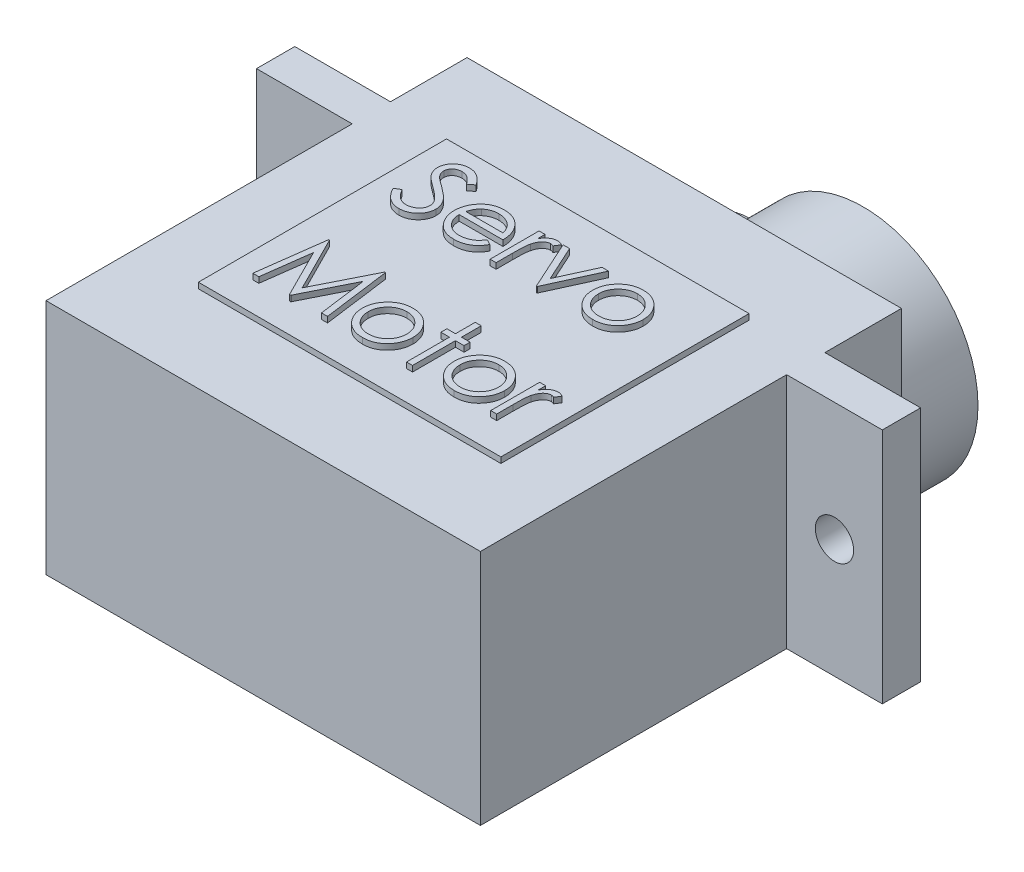
from build123d import *

# Parameters (mm, degrees)
BOSS_EXTRUDE1_DEPTH = 12.4
BOSS_EXTRUDE2_DEPTH = 4
SKETCH3_W           = 15.808123062
SKETCH3_H           = 12.968405358
BOSS_EXTRUDE3_DEPTH = 0.3
BOSS_EXTRUDE4_DEPTH = 0.3
SKETCH5_R           = 2.5
BOSS_EXTRUDE5_DEPTH = 2
CUT_EXTRUDE2_REACH  = 20
SKETCH8_R           = 1


with BuildPart() as part:
    # Sketch1 → Boss-Extrude1 (new body)
    with BuildSketch(Plane(origin=(0, 0, 0), x_dir=(1, 0, 0), z_dir=(0, 1, 0))):
        Polygon((-11.35, 5), (-11.35, -11), (11.35, -11), (11.35, 5), (16.35, 5), (16.35, 7), (11.35, 7), (11.35, 11), (-11.35, 11), (-11.35, 7), (-16.35, 7), (-16.35, 5), align=None)
    extrude(amount=BOSS_EXTRUDE1_DEPTH)

    # Sketch2 → Boss-Extrude2 (add)
    with BuildSketch(Plane(origin=(0, 0, -11), x_dir=(-1, 0, 0), z_dir=(0, 0, -1))):
        with BuildLine():
            Line((0.65, 8.5), (0.104356057, 8.5))
            ThreePointArc((0.104356057, 8.5), (-11.35, 6), (0.104356057, 3.5))
            Line((0.104356057, 3.5), (0.65, 3.5))
            ThreePointArc((0.65, 3.5), (3.15, 6), (0.65, 8.5))
        make_face()
    extrude(amount=BOSS_EXTRUDE2_DEPTH)

    # Sketch3 → Boss-Extrude3 (add)
    with BuildSketch(Plane(origin=(0, 12.4, 0), x_dir=(1, 0, 0), z_dir=(0, 1, 0))):
        Rectangle(SKETCH3_W, SKETCH3_H)
    extrude(amount=BOSS_EXTRUDE3_DEPTH)

    # Sketch4 → Boss-Extrude4 (add)
    with BuildSketch(Plane(origin=(0, 12.7, 0), x_dir=(1, 0, 0), z_dir=(0, 1, 0))):
        with BuildLine():
            Line((-6.767422374, 2.553042472), (-6.471548977, 2.730426286))
            add(Edge.make_bspline(
                [(-6.471548977, 2.730426286), (-6.444030739, 2.684361901), (-6.391306859, 2.596104318), (-6.3033555, 2.476846277), (-6.212222589, 2.37548412), (-6.117233255, 2.292607513), (-6.018967307, 2.227358626), (-5.916783253, 2.181156394), (-5.811025442, 2.152340419), (-5.739051621, 2.148840332), (-5.70311949, 2.147092953)],
                knots=[0, 0, 0, 0, 0.000160901, 0.00030828, 0.000443778, 0.00056903, 0.000685513, 0.000796284, 0.00090427, 0.001011928, 0.001011928, 0.001011928, 0.001011928], degree=3))
            add(Edge.make_bspline(
                [(-5.70311949, 2.147092953), (-5.672432629, 2.147947626), (-5.611595856, 2.149642016), (-5.522033613, 2.165922818), (-5.435051811, 2.190934947), (-5.352443173, 2.226755878), (-5.275347558, 2.270094364), (-5.207740863, 2.322440542), (-5.14929475, 2.381046747), (-5.101485635, 2.446429402), (-5.0648056, 2.516746551), (-5.036613532, 2.588922502), (-5.020968458, 2.66409107), (-5.018611705, 2.714701533), (-5.017422374, 2.740241992)],
                knots=[0, 0, 0, 0, 9.1978e-05, 0.000182347, 0.000272202, 0.000362975, 0.000451852, 0.000536835, 0.000618639, 0.000699414, 0.000778765, 0.000855983, 0.0009312, 0.001007828, 0.001007828, 0.001007828, 0.001007828], degree=3))
            add(Edge.make_bspline(
                [(-5.017422374, 2.740241992), (-5.018896685, 2.769382841), (-5.021893743, 2.82862193), (-5.047225223, 2.916021583), (-5.08707447, 3.002514153), (-5.123837114, 3.056015419), (-5.142923175, 3.083791671)],
                knots=[0, 0, 0, 0, 8.7281e-05, 0.000177429, 0.000270909, 0.000371844, 0.000371844, 0.000371844, 0.000371844], degree=3))
            add(Edge.make_bspline(
                [(-5.142923175, 3.083791671), (-5.15859379, 3.103838495), (-5.191492284, 3.145924293), (-5.248049797, 3.208569529), (-5.314415911, 3.273187948), (-5.388319466, 3.342247005), (-5.472452555, 3.412534801), (-5.564180069, 3.487403079), (-5.665843928, 3.564004656), (-5.737143425, 3.615377222), (-5.773932791, 3.64188462)],
                knots=[0, 0, 0, 0, 7.6319e-05, 0.000160223, 0.000252933, 0.000354147, 0.000463581, 0.000581729, 0.000709336, 0.000845369, 0.000845369, 0.000845369, 0.000845369], degree=3))
            add(Edge.make_bspline(
                [(-5.773932791, 3.64188462), (-5.810756787, 3.668113207), (-5.881161464, 3.71826027), (-5.979620046, 3.792684554), (-6.067664509, 3.860728423), (-6.144903525, 3.923032435), (-6.211303122, 3.97960504), (-6.267386533, 4.029902979), (-6.31172509, 4.07528654), (-6.336380671, 4.104727882), (-6.347450419, 4.117946318)],
                knots=[0, 0, 0, 0, 0.000135623, 0.000259301, 0.000370234, 0.000469439, 0.00055697, 0.000631911, 0.000695377, 0.00074709, 0.00074709, 0.00074709, 0.00074709], degree=3))
            add(Edge.make_bspline(
                [(-6.347450419, 4.117946318), (-6.362922964, 4.138547355), (-6.393351801, 4.179062059), (-6.433517806, 4.242386917), (-6.467656969, 4.307210182), (-6.494419301, 4.373706047), (-6.51695552, 4.440940976), (-6.532113451, 4.509792221), (-6.541604848, 4.57995084), (-6.542576834, 4.62716434), (-6.5430634, 4.650798883)],
                knots=[0, 0, 0, 0, 7.727e-05, 0.000151962, 0.000224716, 0.000296717, 0.00036678, 0.0004372, 0.000507902, 0.000578771, 0.000578771, 0.000578771, 0.000578771], degree=3))
            add(Edge.make_bspline(
                [(-6.5430634, 4.650798883), (-6.541758191, 4.687828657), (-6.539175671, 4.761096721), (-6.517335153, 4.868127551), (-6.48286226, 4.970313969), (-6.434567372, 5.066644302), (-6.372310019, 5.154610283), (-6.300264045, 5.23522377), (-6.214452558, 5.302992352), (-6.120299935, 5.362204411), (-6.017243563, 5.408550336), (-5.90925266, 5.443511316), (-5.796155588, 5.463320574), (-5.719552453, 5.466163339), (-5.680683592, 5.467605774)],
                knots=[0, 0, 0, 0, 0.000110999, 0.000219625, 0.000326272, 0.00043382, 0.000541574, 0.000648775, 0.000756959, 0.000868438, 0.000981703, 0.00109501, 0.001208203, 0.0013248, 0.0013248, 0.0013248, 0.0013248], degree=3))
            add(Edge.make_bspline(
                [(-5.680683592, 5.467605774), (-5.639439492, 5.466183222), (-5.55741814, 5.463354221), (-5.436768924, 5.43875669), (-5.320608208, 5.398056018), (-5.227164943, 5.35186736), (-5.154032182, 5.305735944), (-5.098259449, 5.26371612), (-5.041741998, 5.215341011), (-4.984023944, 5.160481765), (-4.926083284, 5.098635014), (-4.867059832, 5.030224325), (-4.806815563, 4.955667769), (-4.768059703, 4.902443269), (-4.748191605, 4.875157857)],
                knots=[0, 0, 0, 0, 0.000123638, 0.000245877, 0.000367608, 0.000492088, 0.000557638, 0.000626769, 0.000701372, 0.00078072, 0.000865532, 0.000955497, 0.001051745, 0.001152989, 0.001152989, 0.001152989, 0.001152989], degree=3))
            Line((-4.748191605, 4.875157857), (-5.032145932, 4.659913466))
            add(Edge.make_bspline(
                [(-5.032145932, 4.659913466), (-5.049291864, 4.682002156), (-5.082310921, 4.72453981), (-5.132440408, 4.784111125), (-5.179689056, 4.838527605), (-5.226239456, 4.885792733), (-5.269633087, 4.928494866), (-5.31175013, 4.965054623), (-5.351984481, 4.995830218), (-5.402701392, 5.028673778), (-5.46641911, 5.061230282), (-5.546403646, 5.08877936), (-5.629989921, 5.105334422), (-5.686919553, 5.107523309), (-5.715739682, 5.108631415)],
                knots=[0, 0, 0, 0, 8.3877e-05, 0.000161528, 0.000233552, 0.000299993, 0.000360485, 0.000416152, 0.000467195, 0.000512312, 0.000597287, 0.000681099, 0.000765389, 0.000851809, 0.000851809, 0.000851809, 0.000851809], degree=3))
            add(Edge.make_bspline(
                [(-5.715739682, 5.108631415), (-5.751896204, 5.107419715), (-5.821620652, 5.105083065), (-5.920610888, 5.07956308), (-6.009704813, 5.03938122), (-6.086257378, 4.983066242), (-6.149994355, 4.916345249), (-6.196099814, 4.839566394), (-6.223849978, 4.754783991), (-6.227236258, 4.695642335), (-6.228960836, 4.66552244)],
                knots=[0, 0, 0, 0, 0.000108248, 0.000208746, 0.00030443, 0.000399793, 0.000492054, 0.00057947, 0.000666386, 0.000756591, 0.000756591, 0.000756591, 0.000756591], degree=3))
            add(Edge.make_bspline(
                [(-6.228960836, 4.66552244), (-6.228567709, 4.646770962), (-6.227780813, 4.609237342), (-6.216806015, 4.55378592), (-6.202706686, 4.498474581), (-6.180364055, 4.443551998), (-6.149518751, 4.388057639), (-6.109013575, 4.331035901), (-6.058000263, 4.271984193), (-6.018923251, 4.233576819), (-5.998291765, 4.213298883)],
                knots=[0, 0, 0, 0, 5.616e-05, 0.000112411, 0.000169046, 0.000227244, 0.000289691, 0.000359134, 0.000436702, 0.000523463, 0.000523463, 0.000523463, 0.000523463], degree=3))
            add(Edge.make_bspline(
                [(-5.998291765, 4.213298883), (-5.990630393, 4.206461857), (-5.972428726, 4.190218648), (-5.9391528, 4.163626368), (-5.895210002, 4.130823595), (-5.8417478, 4.090236279), (-5.777780439, 4.043154817), (-5.703300883, 3.990181205), (-5.61913935, 3.929595746), (-5.559417434, 3.887238205), (-5.527839041, 3.864841351)],
                knots=[0, 0, 0, 0, 3.0802e-05, 7.3177e-05, 0.000127725, 0.000195314, 0.000274544, 0.000365991, 0.000469501, 0.000585644, 0.000585644, 0.000585644, 0.000585644], degree=3))
            add(Edge.make_bspline(
                [(-5.527839041, 3.864841351), (-5.489853128, 3.837199991), (-5.416298671, 3.783676329), (-5.311641091, 3.703260649), (-5.216747283, 3.624612881), (-5.13128408, 3.548235274), (-5.054407171, 3.474707181), (-4.98696945, 3.403144), (-4.92828377, 3.334058427), (-4.865104552, 3.245485852), (-4.800546732, 3.136704768), (-4.745105225, 3.003426529), (-4.710146877, 2.869630208), (-4.705575362, 2.779703372), (-4.70331981, 2.735334139)],
                knots=[0, 0, 0, 0, 0.000140932, 0.000272896, 0.000395881, 0.000510584, 0.000616697, 0.000714904, 0.000805482, 0.000888372, 0.001041088, 0.001183793, 0.001320341, 0.001453327, 0.001453327, 0.001453327, 0.001453327], degree=3))
            add(Edge.make_bspline(
                [(-4.70331981, 2.735334139), (-4.703976948, 2.703955774), (-4.705278463, 2.64180839), (-4.720239377, 2.550553313), (-4.742159042, 2.461922444), (-4.775196276, 2.377011331), (-4.815519434, 2.294266569), (-4.866685682, 2.215858668), (-4.925993367, 2.14005227), (-4.994027132, 2.068868778), (-5.068473034, 2.003522582), (-5.147156729, 1.945393521), (-5.230207002, 1.896925197), (-5.317173319, 1.857374355), (-5.408075655, 1.826440838), (-5.502883439, 1.804027969), (-5.60175295, 1.790272258), (-5.668953432, 1.788844496), (-5.70311949, 1.788118594)],
                knots=[0, 0, 0, 0, 9.4044e-05, 0.000186263, 0.000276729, 0.000367488, 0.000459046, 0.000552398, 0.000647774, 0.000747454, 0.000847311, 0.000944634, 0.001040472, 0.001135227, 0.001230788, 0.001328063, 0.00142712, 0.00152957, 0.00152957, 0.00152957, 0.00152957], degree=3))
            add(Edge.make_bspline(
                [(-5.70311949, 1.788118594), (-5.729554833, 1.788629776), (-5.782092593, 1.789645701), (-5.859802074, 1.798626982), (-5.935941664, 1.811334085), (-6.009555946, 1.831508155), (-6.081593357, 1.855985132), (-6.151740592, 1.886123465), (-6.220031646, 1.922240666), (-6.286849229, 1.963535691), (-6.352023403, 2.011593435), (-6.414942871, 2.067566932), (-6.477672057, 2.129912437), (-6.538359453, 2.200323), (-6.598232597, 2.277661083), (-6.656111007, 2.362650266), (-6.713192724, 2.45482762), (-6.749008192, 2.519692706), (-6.767422374, 2.553042472)],
                knots=[0, 0, 0, 0, 7.9276e-05, 0.000157554, 0.000234438, 0.000310629, 0.000386236, 0.000462555, 0.000539392, 0.000617798, 0.000698008, 0.000781971, 0.000870217, 0.00096315, 0.001060616, 0.001163492, 0.001271478, 0.00138575, 0.00138575, 0.00138575, 0.00138575], degree=3))
        make_face()
        with BuildLine():
            Line((-1.975956028, 2.685554492), (-1.696909554, 2.539020036))
            add(Edge.make_bspline(
                [(-1.696909554, 2.539020036), (-1.719146149, 2.499576705), (-1.762409757, 2.422835602), (-1.836810505, 2.317403742), (-1.914802578, 2.222556026), (-1.999906546, 2.140826372), (-2.089576225, 2.069574987), (-2.18430888, 2.007237162), (-2.284597697, 1.954118642), (-2.390447422, 1.909366114), (-2.502746973, 1.87495662), (-2.62176849, 1.850652399), (-2.747739985, 1.83562913), (-2.834086165, 1.833883989), (-2.878299778, 1.832990389)],
                knots=[0, 0, 0, 0, 0.000135759, 0.000264133, 0.000386579, 0.000503597, 0.000617365, 0.000729763, 0.000843304, 0.000957371, 0.001074023, 0.001195027, 0.001321389, 0.001453992, 0.001453992, 0.001453992, 0.001453992], degree=3))
            add(Edge.make_bspline(
                [(-2.878299778, 1.832990389), (-2.927441756, 1.834137564), (-3.023303517, 1.836375371), (-3.162843264, 1.855667835), (-3.294222683, 1.887140194), (-3.417434386, 1.931105736), (-3.532176639, 1.98853306), (-3.638677493, 2.058492542), (-3.737497019, 2.140624796), (-3.825521229, 2.23564124), (-3.904765111, 2.337323197), (-3.974690931, 2.443279082), (-4.033148362, 2.553242306), (-4.080700972, 2.66651283), (-4.119105837, 2.782376724), (-4.145872541, 2.901888191), (-4.161302289, 3.024723775), (-4.163666735, 3.107821111), (-4.164858272, 3.14969712)],
                knots=[0, 0, 0, 0, 0.000147371, 0.000287478, 0.000421649, 0.000552053, 0.000679042, 0.000805636, 0.000933558, 0.00106351, 0.001193382, 0.001319977, 0.001443869, 0.001566405, 0.001688128, 0.001809576, 0.001933238, 0.002058864, 0.002058864, 0.002058864, 0.002058864], degree=3))
            add(Edge.make_bspline(
                [(-4.164858272, 3.14969712), (-4.16379913, 3.18899195), (-4.161700052, 3.266869115), (-4.148469265, 3.382134659), (-4.125020972, 3.494163112), (-4.092844648, 3.60304756), (-4.051293401, 3.708605694), (-4.000461182, 3.810901757), (-3.940268804, 3.909826897), (-3.893796131, 3.972230031), (-3.870387118, 4.003663466)],
                knots=[0, 0, 0, 0, 0.000117891, 0.000233644, 0.000347498, 0.000460856, 0.000573868, 0.000687374, 0.000803169, 0.000920699, 0.000920699, 0.000920699, 0.000920699], degree=3))
            add(Edge.make_bspline(
                [(-3.870387118, 4.003663466), (-3.838679435, 4.041532336), (-3.776268488, 4.116070486), (-3.670712133, 4.214008812), (-3.556411937, 4.296052587), (-3.434800311, 4.364059724), (-3.304463837, 4.415733371), (-3.167154545, 4.454240953), (-3.021308959, 4.475818964), (-2.921603738, 4.478866797), (-2.870587438, 4.480426286)],
                knots=[0, 0, 0, 0, 0.000148071, 0.000291452, 0.00043058, 0.000569298, 0.000708346, 0.00085021, 0.000996268, 0.001149307, 0.001149307, 0.001149307, 0.001149307], degree=3))
            add(Edge.make_bspline(
                [(-2.870587438, 4.480426286), (-2.818139833, 4.479072238), (-2.715249587, 4.476415902), (-2.565217466, 4.451789569), (-2.423256749, 4.412737014), (-2.289424245, 4.357583224), (-2.163706384, 4.286423672), (-2.046920335, 4.198281831), (-1.937068822, 4.095863743), (-1.873160243, 4.017100534), (-1.840639522, 3.977020838)],
                knots=[0, 0, 0, 0, 0.000157241, 0.00030847, 0.000454763, 0.000598116, 0.000741606, 0.000886879, 0.001036172, 0.001190853, 0.001190853, 0.001190853, 0.001190853], degree=3))
            add(Edge.make_bspline(
                [(-1.840639522, 3.977020838), (-1.818512583, 3.946817256), (-1.77440599, 3.886611138), (-1.71915889, 3.788439981), (-1.671201495, 3.685729386), (-1.632868534, 3.576819089), (-1.601829033, 3.462999509), (-1.579372214, 3.343456964), (-1.566202596, 3.218227053), (-1.563613898, 3.132900497), (-1.562294169, 3.089400645)],
                knots=[0, 0, 0, 0, 0.000112234, 0.000223721, 0.000337279, 0.000451932, 0.000569628, 0.000690912, 0.000816421, 0.00094695, 0.00094695, 0.00094695, 0.00094695], degree=3))
            Line((-1.562294169, 3.089400645), (-3.850755707, 3.089400645))
            add(Edge.make_bspline(
                [(-3.850755707, 3.089400645), (-3.849216101, 3.055700181), (-3.846188527, 2.989429577), (-3.832073384, 2.892458794), (-3.80982461, 2.800085452), (-3.778555548, 2.71300241), (-3.740688702, 2.630072283), (-3.694302985, 2.551910246), (-3.638963432, 2.478872316), (-3.577237732, 2.410305178), (-3.508530637, 2.349244417), (-3.43624789, 2.294592641), (-3.359354325, 2.248787044), (-3.278456241, 2.211607154), (-3.193684456, 2.182500838), (-3.105012261, 2.162633017), (-3.012614145, 2.149325911), (-2.94962841, 2.147846245), (-2.917562599, 2.147092953)],
                knots=[0, 0, 0, 0, 0.000101159, 0.000198924, 0.000293472, 0.000385722, 0.000476069, 0.000566611, 0.000657757, 0.000750573, 0.000842919, 0.000933083, 0.001022062, 0.001110842, 0.001199752, 0.001290403, 0.001383113, 0.001479259, 0.001479259, 0.001479259, 0.001479259], degree=3))
            add(Edge.make_bspline(
                [(-2.917562599, 2.147092953), (-2.886211451, 2.14770101), (-2.82400476, 2.148907511), (-2.731363903, 2.160639422), (-2.640224375, 2.179609697), (-2.550963392, 2.205499687), (-2.465392546, 2.23707654), (-2.386146996, 2.275179397), (-2.31326678, 2.317329144), (-2.245149814, 2.365538819), (-2.17907882, 2.424547006), (-2.113536334, 2.498182727), (-2.043259681, 2.585270255), (-1.999270088, 2.650815921), (-1.975956028, 2.685554492)],
                knots=[0, 0, 0, 0, 9.4016e-05, 0.000186545, 0.000279636, 0.000373054, 0.000465125, 0.000552934, 0.000636508, 0.000717442, 0.000802858, 0.000901616, 0.001012865, 0.001138311, 0.001138311, 0.001138311, 0.001138311], degree=3))
        make_face()
        with BuildLine():
            add(Edge.make_bspline(
                [(-1.876396733, 3.403503209), (-1.887893358, 3.445166083), (-1.910020659, 3.525353704), (-1.956257024, 3.636394594), (-2.008328564, 3.735082495), (-2.069950296, 3.820662128), (-2.139769021, 3.896665641), (-2.220414204, 3.963084226), (-2.310850097, 4.022501678), (-2.410609238, 4.072654177), (-2.516251023, 4.115344036), (-2.626857215, 4.143969151), (-2.739715003, 4.163578694), (-2.816049289, 4.165404802), (-2.854461637, 4.166323722)],
                knots=[0, 0, 0, 0, 0.000129543, 0.000249328, 0.000360065, 0.000463575, 0.000564789, 0.000668832, 0.000776175, 0.000888744, 0.001003316, 0.001117263, 0.001230914, 0.001346035, 0.001346035, 0.001346035, 0.001346035], degree=3))
            add(Edge.make_bspline(
                [(-2.854461637, 4.166323722), (-2.885811075, 4.165712051), (-2.947782325, 4.164502905), (-3.039083393, 4.153032775), (-3.126763092, 4.134072931), (-3.211468379, 4.108107974), (-3.292089248, 4.073499371), (-3.370284016, 4.032916145), (-3.444064412, 3.983374561), (-3.490205708, 3.945615706), (-3.513516124, 3.926540068)],
                knots=[0, 0, 0, 0, 9.4016e-05, 0.000185849, 0.000275511, 0.000362884, 0.000451173, 0.00053836, 0.000626838, 0.000717174, 0.000717174, 0.000717174, 0.000717174], degree=3))
            add(Edge.make_bspline(
                [(-3.513516124, 3.926540068), (-3.530209406, 3.911445753), (-3.56399254, 3.880898537), (-3.609133062, 3.82826933), (-3.652353535, 3.771517768), (-3.691687187, 3.708472643), (-3.727764774, 3.639851864), (-3.761524751, 3.566234229), (-3.791911163, 3.487061099), (-3.809007273, 3.43188866), (-3.817802983, 3.403503209)],
                knots=[0, 0, 0, 0, 6.7454e-05, 0.00013651, 0.000207604, 0.000281328, 0.000359112, 0.000440057, 0.000524171, 0.000613305, 0.000613305, 0.000613305, 0.000613305], degree=3))
            Line((-3.817802983, 3.403503209), (-1.876396733, 3.403503209))
        make_face(mode=Mode.SUBTRACT)
        with BuildLine():
            Line((-1.023832631, 4.435554492), (-0.709730066, 4.435554492))
            Line((-0.709730066, 4.435554492), (-0.709730066, 4.059052088))
            add(Edge.make_bspline(
                [(-0.709730066, 4.059052088), (-0.686541308, 4.094107916), (-0.642192987, 4.161151915), (-0.568480057, 4.249821216), (-0.492976726, 4.323236263), (-0.415321539, 4.381739782), (-0.334943439, 4.425552901), (-0.253606487, 4.457645936), (-0.170031017, 4.476623251), (-0.113869093, 4.47915691), (-0.085731669, 4.480426286)],
                knots=[0, 0, 0, 0, 0.000126023, 0.000241017, 0.000345147, 0.000441342, 0.00053171, 0.000618946, 0.000702978, 0.000787349, 0.000787349, 0.000787349, 0.000787349], degree=3))
            add(Edge.make_bspline(
                [(-0.085731669, 4.480426286), (-0.063905343, 4.47923576), (-0.018996257, 4.476786174), (0.048986332, 4.459575349), (0.119029784, 4.432097327), (0.164172172, 4.406257104), (0.187705831, 4.392786062)],
                knots=[0, 0, 0, 0, 6.5445e-05, 0.000134658, 0.00020926, 0.000290509, 0.000290509, 0.000290509, 0.000290509], degree=3))
            Line((0.187705831, 4.392786062), (0.015229869, 4.120750806))
            add(Edge.make_bspline(
                [(0.015229869, 4.120750806), (0.000120848, 4.127491072), (-0.028558966, 4.140285387), (-0.070513533, 4.155427397), (-0.109194869, 4.164343313), (-0.133838428, 4.165694031), (-0.145327022, 4.166323722)],
                knots=[0, 0, 0, 0, 4.9621e-05, 9.4191e-05, 0.00013366, 0.000168129, 0.000168129, 0.000168129, 0.000168129], degree=3))
            add(Edge.make_bspline(
                [(-0.145327022, 4.166323722), (-0.170532755, 4.164643685), (-0.221945145, 4.161216896), (-0.297429644, 4.134278088), (-0.37067685, 4.090752848), (-0.428848512, 4.042481736), (-0.473890765, 3.995933939), (-0.506030991, 3.955285536), (-0.535513738, 3.909706904), (-0.563683958, 3.859977221), (-0.589350252, 3.805247375), (-0.613304921, 3.746064161), (-0.634963784, 3.682359032), (-0.647314029, 3.637976512), (-0.653640323, 3.615241992)],
                knots=[0, 0, 0, 0, 7.549e-05, 0.000153978, 0.000237553, 0.000330197, 0.000379784, 0.000431685, 0.000485357, 0.000542493, 0.000603021, 0.000666557, 0.00073396, 0.000804745, 0.000804745, 0.000804745, 0.000804745], degree=3))
            add(Edge.make_bspline(
                [(-0.653640323, 3.615241992), (-0.658372716, 3.594964818), (-0.668854608, 3.550052419), (-0.679046146, 3.474703895), (-0.689115664, 3.385680236), (-0.696212282, 3.282733643), (-0.702790324, 3.166121199), (-0.706500406, 3.035665253), (-0.709603547, 2.891231902), (-0.709686614, 2.790257549), (-0.709730066, 2.737437504)],
                knots=[0, 0, 0, 0, 6.2435e-05, 0.000138289, 0.000227871, 0.000331224, 0.000447781, 0.000578258, 0.000722716, 0.000881171, 0.000881171, 0.000881171, 0.000881171], degree=3))
            Line((-0.709730066, 2.737437504), (-0.709730066, 1.877862184))
            Line((-0.709730066, 1.877862184), (-1.023832631, 1.877862184))
            Line((-1.023832631, 1.877862184), (-1.023832631, 4.435554492))
        make_face()
        Polygon((0.232577626, 4.435554492), (0.572621696, 4.435554492), (1.42168019, 2.573375004), (2.270738684, 4.435554492), (2.610782754, 4.435554492), (1.444116087, 1.877862184), (1.399244293, 1.877862184), align=None)
        with BuildLine():
            add(Edge.make_bspline(
                [(4.384620895, 4.480426286), (4.432612168, 4.479404395), (4.526711325, 4.477400716), (4.664519211, 4.455985751), (4.796064347, 4.423238386), (4.921850539, 4.377966824), (5.040266835, 4.317284874), (5.153038079, 4.244875583), (5.259855088, 4.159092989), (5.323878117, 4.092734921), (5.356375703, 4.059052088)],
                knots=[0, 0, 0, 0, 0.000143868, 0.000282091, 0.000417278, 0.000550139, 0.000682145, 0.000815559, 0.000951665, 0.001091969, 0.001091969, 0.001091969, 0.001091969], degree=3))
            add(Edge.make_bspline(
                [(5.356375703, 4.059052088), (5.384357657, 4.026838102), (5.439780037, 3.96303356), (5.510845756, 3.859577947), (5.572067316, 3.752437846), (5.621130277, 3.640190519), (5.659815301, 3.523815848), (5.687280997, 3.402913837), (5.703617932, 3.27775149), (5.705820899, 3.192747652), (5.7069366, 3.14969712)],
                knots=[0, 0, 0, 0, 0.000127922, 0.000253368, 0.000375813, 0.000497617, 0.000620225, 0.000743195, 0.000869033, 0.000998161, 0.000998161, 0.000998161, 0.000998161], degree=3))
            add(Edge.make_bspline(
                [(5.7069366, 3.14969712), (5.705955263, 3.106397062), (5.704016095, 3.020834129), (5.685672478, 2.894814763), (5.657141392, 2.77261994), (5.616309554, 2.654761247), (5.563951445, 2.540878419), (5.500060757, 2.43146887), (5.42418914, 2.326316737), (5.338185143, 2.226314898), (5.243133267, 2.134148684), (5.140017119, 2.053820414), (5.030863085, 1.98499889), (4.914219732, 1.929562474), (4.791152245, 1.885852774), (4.661395177, 1.855152757), (4.525150107, 1.836591073), (4.432122885, 1.8342075), (4.384620895, 1.832990389)],
                knots=[0, 0, 0, 0, 0.000129829, 0.000256548, 0.000381202, 0.000505812, 0.000630045, 0.000756669, 0.000885282, 0.001018518, 0.001151902, 0.001281775, 0.001409974, 0.001538236, 0.001668405, 0.001801048, 0.001937587, 0.002080055, 0.002080055, 0.002080055, 0.002080055], degree=3))
            add(Edge.make_bspline(
                [(4.384620895, 1.832990389), (4.336886176, 1.834211585), (4.243395316, 1.83660336), (4.106669334, 1.855080642), (3.976679715, 1.885838625), (3.853451116, 1.929706118), (3.73630627, 1.985000661), (3.626519773, 2.053612351), (3.523319857, 2.134172506), (3.428247873, 2.226308443), (3.342249267, 2.3263184), (3.266376259, 2.431468438), (3.202485933, 2.540878532), (3.150127729, 2.654761217), (3.109295916, 2.772619948), (3.080764823, 2.894814761), (3.062421209, 3.020834129), (3.06048204, 3.106397062), (3.059500703, 3.14969712)],
                knots=[0, 0, 0, 0, 0.000143168, 0.000280402, 0.000413045, 0.000543214, 0.000672108, 0.000800903, 0.000930775, 0.00106416, 0.001197395, 0.001326009, 0.001452632, 0.001576866, 0.001701476, 0.00182613, 0.001952849, 0.002082678, 0.002082678, 0.002082678, 0.002082678], degree=3))
            add(Edge.make_bspline(
                [(3.059500703, 3.14969712), (3.060624013, 3.192513666), (3.062847975, 3.277283068), (3.079168484, 3.402210129), (3.10652704, 3.522907518), (3.145258437, 3.638832994), (3.194773627, 3.75058843), (3.255134915, 3.857993261), (3.326925548, 3.960981061), (3.382127499, 4.024703141), (3.4100616, 4.056948722)],
                knots=[0, 0, 0, 0, 0.000128428, 0.000254265, 0.000377235, 0.000499178, 0.000620341, 0.000743397, 0.000868267, 0.000996189, 0.000996189, 0.000996189, 0.000996189], degree=3))
            add(Edge.make_bspline(
                [(3.4100616, 4.056948722), (3.442510191, 4.090923662), (3.506326055, 4.157741358), (3.613674783, 4.243273882), (3.726168604, 4.317189956), (3.84589353, 4.376666171), (3.971576388, 4.423504689), (4.103795631, 4.456070204), (4.242071146, 4.477323559), (4.336630767, 4.479381737), (4.384620895, 4.480426286)],
                knots=[0, 0, 0, 0, 0.000140798, 0.000276904, 0.000410699, 0.000543958, 0.000677061, 0.000812248, 0.000951858, 0.001095726, 0.001095726, 0.001095726, 0.001095726], degree=3))
        make_face()
        with BuildLine():
            add(Edge.make_bspline(
                [(4.383218651, 4.166323722), (4.34928104, 4.165359131), (4.282281911, 4.163454848), (4.183662327, 4.148970943), (4.088722173, 4.126023439), (3.997281329, 4.093419383), (3.909648156, 4.051320484), (3.825738754, 3.999612124), (3.745306314, 3.938979167), (3.669924251, 3.869516496), (3.600741938, 3.793637501), (3.540263962, 3.712789142), (3.488838856, 3.628282796), (3.445998697, 3.540030585), (3.414091508, 3.447138171), (3.390918486, 3.35065754), (3.376448246, 3.250392123), (3.374561867, 3.182231105), (3.373603267, 3.147593754)],
                knots=[0, 0, 0, 0, 0.000101781, 0.000200935, 0.000298373, 0.000394396, 0.000491609, 0.000589491, 0.000689611, 0.000793323, 0.000896562, 0.000997243, 0.001095722, 0.001192936, 0.001290943, 0.001389744, 0.001490285, 0.001594167, 0.001594167, 0.001594167, 0.001594167], degree=3))
            add(Edge.make_bspline(
                [(3.373603267, 3.147593754), (3.375210091, 3.102841727), (3.378399335, 3.014017322), (3.404334571, 2.883206199), (3.447720851, 2.757624347), (3.506308131, 2.638007961), (3.57971435, 2.527335683), (3.666201416, 2.428664198), (3.764841117, 2.343478387), (3.874457617, 2.272797541), (3.992811935, 2.216637786), (4.118068256, 2.17683881), (4.24870895, 2.150967118), (4.337989681, 2.148395643), (4.383218651, 2.147092953)],
                knots=[0, 0, 0, 0, 0.000134178, 0.000266319, 0.000398243, 0.00053182, 0.000664828, 0.000795487, 0.000924236, 0.001054533, 0.001185628, 0.001316003, 0.001448011, 0.001583547, 0.001583547, 0.001583547, 0.001583547], degree=3))
            add(Edge.make_bspline(
                [(4.383218651, 2.147092953), (4.42844502, 2.148403233), (4.517720616, 2.15098969), (4.648179793, 2.17670851), (4.773093765, 2.216812171), (4.891325153, 2.272734381), (5.000891756, 2.343746795), (5.100240877, 2.428183172), (5.185989489, 2.527597024), (5.259323093, 2.638154553), (5.318869836, 2.757438905), (5.362053038, 2.883229377), (5.388050624, 3.014011419), (5.391231453, 3.10283975), (5.392834036, 3.147593754)],
                knots=[0, 0, 0, 0, 0.000135536, 0.000267545, 0.000397252, 0.000528347, 0.000658644, 0.000787925, 0.000918122, 0.00105113, 0.001185017, 0.001316942, 0.001449082, 0.00158326, 0.00158326, 0.00158326, 0.00158326], degree=3))
            add(Edge.make_bspline(
                [(5.392834036, 3.147593754), (5.391875766, 3.182231312), (5.389990037, 3.250392738), (5.375515073, 3.350655191), (5.352359533, 3.447146788), (5.320387916, 3.539998791), (5.277733902, 3.628511296), (5.225317109, 3.712541023), (5.165086083, 3.793917569), (5.095068962, 3.869271209), (5.019765585, 3.939006246), (4.939300546, 3.999635635), (4.855515568, 4.051093231), (4.768136985, 4.093779471), (4.676684417, 4.125726812), (4.581877288, 4.149103443), (4.483678478, 4.16339364), (4.416919435, 4.165340781), (4.383218651, 4.166323722)],
                knots=[0, 0, 0, 0, 0.000103882, 0.000204424, 0.000303225, 0.000401232, 0.000498445, 0.000597291, 0.000697972, 0.000801684, 0.000905395, 0.001005516, 0.001103397, 0.001199979, 0.001296663, 0.00139342, 0.001492573, 0.001593654, 0.001593654, 0.001593654, 0.001593654], degree=3))
        make_face(mode=Mode.SUBTRACT)
        Polygon((-6.587935195, -4.955471149), (-6.125895932, -1.455471149), (-6.081024137, -1.455471149), (-4.636012118, -4.327266021), (-3.194505707, -1.455471149), (-3.148932791, -1.455471149), (-2.684089041, -4.955471149), (-2.999593849, -4.955471149), (-3.334730066, -2.437041662), (-4.598151541, -4.955471149), (-4.668964842, -4.955471149), (-5.937294169, -2.431432688), (-6.271729265, -4.955471149), align=None)
        with BuildLine():
            add(Edge.make_bspline(
                [(-0.82050731, -2.352907047), (-0.772516037, -2.353928938), (-0.67841688, -2.355932617), (-0.540608994, -2.377347582), (-0.409063858, -2.410094947), (-0.283277666, -2.455366509), (-0.16486137, -2.51604846), (-0.052090126, -2.588457751), (0.054726883, -2.674240344), (0.118749912, -2.740598413), (0.151247498, -2.774281246)],
                knots=[0, 0, 0, 0, 0.000143868, 0.000282091, 0.000417278, 0.000550139, 0.000682145, 0.000815559, 0.000951665, 0.001091969, 0.001091969, 0.001091969, 0.001091969], degree=3))
            add(Edge.make_bspline(
                [(0.151247498, -2.774281246), (0.179229452, -2.806495231), (0.234651832, -2.870299774), (0.305717551, -2.973755387), (0.366939111, -3.080895487), (0.416002072, -3.193142814), (0.454687096, -3.309517485), (0.482152792, -3.430419496), (0.498489727, -3.555581843), (0.500692694, -3.640585681), (0.501808395, -3.683636214)],
                knots=[0, 0, 0, 0, 0.000127922, 0.000253368, 0.000375813, 0.000497617, 0.000620225, 0.000743195, 0.000869033, 0.000998161, 0.000998161, 0.000998161, 0.000998161], degree=3))
            add(Edge.make_bspline(
                [(0.501808395, -3.683636214), (0.500827058, -3.726936271), (0.498887889, -3.812499205), (0.480544273, -3.93851857), (0.452013187, -4.060713393), (0.411181349, -4.178572087), (0.35882324, -4.292454914), (0.294932552, -4.401864464), (0.219060935, -4.507016597), (0.133056938, -4.607018435), (0.038005062, -4.69918465), (-0.065111086, -4.779512919), (-0.17426512, -4.848334444), (-0.290908473, -4.903770859), (-0.41397596, -4.94748056), (-0.543733028, -4.978180576), (-0.679978098, -4.99674226), (-0.77300532, -4.999125833), (-0.82050731, -5.000342944)],
                knots=[0, 0, 0, 0, 0.000129829, 0.000256548, 0.000381202, 0.000505812, 0.000630045, 0.000756669, 0.000885282, 0.001018518, 0.001151902, 0.001281775, 0.001409974, 0.001538236, 0.001668405, 0.001801048, 0.001937587, 0.002080055, 0.002080055, 0.002080055, 0.002080055], degree=3))
            add(Edge.make_bspline(
                [(-0.82050731, -5.000342944), (-0.86824203, -4.999121748), (-0.961732889, -4.996729974), (-1.098458871, -4.978252691), (-1.22844849, -4.947494708), (-1.351677089, -4.903627216), (-1.468821936, -4.848332672), (-1.578608433, -4.779720982), (-1.681808348, -4.699160827), (-1.776880333, -4.60702489), (-1.862878938, -4.507014934), (-1.938751946, -4.401864895), (-2.002642272, -4.292454802), (-2.055000476, -4.178572117), (-2.095832289, -4.060713385), (-2.124363382, -3.938518573), (-2.142706996, -3.812499204), (-2.144646165, -3.726936271), (-2.145627502, -3.683636214)],
                knots=[0, 0, 0, 0, 0.000143168, 0.000280402, 0.000413045, 0.000543214, 0.000672108, 0.000800903, 0.000930775, 0.00106416, 0.001197395, 0.001326009, 0.001452632, 0.001576866, 0.001701476, 0.00182613, 0.001952849, 0.002082678, 0.002082678, 0.002082678, 0.002082678], degree=3))
            add(Edge.make_bspline(
                [(-2.145627502, -3.683636214), (-2.144504192, -3.640819668), (-2.142280231, -3.556050265), (-2.125959721, -3.431123205), (-2.098601165, -3.310425816), (-2.059869769, -3.19450034), (-2.010354578, -3.082744904), (-1.94999329, -2.975340073), (-1.878202657, -2.872352272), (-1.823000706, -2.808630192), (-1.795066605, -2.776384611)],
                knots=[0, 0, 0, 0, 0.000128428, 0.000254265, 0.000377235, 0.000499178, 0.000620341, 0.000743397, 0.000868267, 0.000996189, 0.000996189, 0.000996189, 0.000996189], degree=3))
            add(Edge.make_bspline(
                [(-1.795066605, -2.776384611), (-1.762618014, -2.742409672), (-1.69880215, -2.675591976), (-1.591453422, -2.590059451), (-1.478959601, -2.516143378), (-1.359234675, -2.456667162), (-1.233551817, -2.409828644), (-1.101332575, -2.377263129), (-0.963057059, -2.356009774), (-0.868497438, -2.353951597), (-0.82050731, -2.352907047)],
                knots=[0, 0, 0, 0, 0.000140798, 0.000276904, 0.000410699, 0.000543958, 0.000677061, 0.000812248, 0.000951858, 0.001095726, 0.001095726, 0.001095726, 0.001095726], degree=3))
        make_face()
        with BuildLine():
            add(Edge.make_bspline(
                [(-0.821909554, -2.667009611), (-0.855847165, -2.667974203), (-0.922846294, -2.669878485), (-1.021465878, -2.68436239), (-1.116406032, -2.707309894), (-1.207846876, -2.73991395), (-1.295480049, -2.782012849), (-1.379389451, -2.833721209), (-1.459821891, -2.894354166), (-1.535203954, -2.963816838), (-1.604386267, -3.039695832), (-1.664864243, -3.120544191), (-1.71628935, -3.205050537), (-1.759129509, -3.293302748), (-1.791036697, -3.386195162), (-1.814209719, -3.482675793), (-1.82867996, -3.58294121), (-1.830566338, -3.651102228), (-1.831524938, -3.685739579)],
                knots=[0, 0, 0, 0, 0.000101781, 0.000200935, 0.000298373, 0.000394396, 0.000491609, 0.000589491, 0.000689611, 0.000793323, 0.000896562, 0.000997243, 0.001095722, 0.001192936, 0.001290943, 0.001389744, 0.001490285, 0.001594167, 0.001594167, 0.001594167, 0.001594167], degree=3))
            add(Edge.make_bspline(
                [(-1.831524938, -3.685739579), (-1.829918115, -3.730491606), (-1.82672887, -3.819316012), (-1.800793634, -3.950127134), (-1.757407354, -4.075708986), (-1.698820074, -4.195325372), (-1.625413855, -4.30599765), (-1.538926789, -4.404669135), (-1.440287088, -4.489854946), (-1.330670588, -4.560535792), (-1.21231627, -4.616695548), (-1.087059949, -4.656494523), (-0.956419255, -4.682366216), (-0.867138524, -4.68493769), (-0.821909554, -4.68624038)],
                knots=[0, 0, 0, 0, 0.000134178, 0.000266319, 0.000398243, 0.00053182, 0.000664828, 0.000795487, 0.000924236, 0.001054533, 0.001185628, 0.001316003, 0.001448011, 0.001583547, 0.001583547, 0.001583547, 0.001583547], degree=3))
            add(Edge.make_bspline(
                [(-0.821909554, -4.68624038), (-0.776683185, -4.6849301), (-0.687407589, -4.682343643), (-0.556948412, -4.656624823), (-0.43203444, -4.616521163), (-0.313803053, -4.560598953), (-0.204236449, -4.489586538), (-0.104887328, -4.405150161), (-0.019138717, -4.30573631), (0.054194888, -4.195178781), (0.113741631, -4.075894429), (0.156924833, -3.950103956), (0.182922419, -3.819321914), (0.186103247, -3.730493584), (0.187705831, -3.685739579)],
                knots=[0, 0, 0, 0, 0.000135536, 0.000267545, 0.000397252, 0.000528347, 0.000658644, 0.000787925, 0.000918122, 0.00105113, 0.001185017, 0.001316942, 0.001449082, 0.00158326, 0.00158326, 0.00158326, 0.00158326], degree=3))
            add(Edge.make_bspline(
                [(0.187705831, -3.685739579), (0.186747561, -3.651102021), (0.184861832, -3.582940596), (0.170386867, -3.482678142), (0.147231328, -3.386186545), (0.115259711, -3.293334542), (0.072605697, -3.204822038), (0.020188904, -3.120792311), (-0.040042122, -3.039415765), (-0.110059243, -2.964062124), (-0.185362621, -2.894327087), (-0.265827659, -2.833697698), (-0.349612637, -2.782240102), (-0.43699122, -2.739553862), (-0.528443788, -2.707606522), (-0.623250917, -2.68422989), (-0.721449727, -2.669939693), (-0.78820877, -2.667992552), (-0.821909554, -2.667009611)],
                knots=[0, 0, 0, 0, 0.000103882, 0.000204424, 0.000303225, 0.000401232, 0.000498445, 0.000597291, 0.000697972, 0.000801684, 0.000905395, 0.001005516, 0.001103397, 0.001199979, 0.001296663, 0.00139342, 0.001492573, 0.001593654, 0.001593654, 0.001593654, 0.001593654], degree=3))
        make_face(mode=Mode.SUBTRACT)
        Polygon((1.444116087, -1.36572756), (1.758218651, -1.36572756), (1.758218651, -2.397778842), (2.2069366, -2.397778842), (2.2069366, -2.711881406), (1.758218651, -2.711881406), (1.758218651, -4.955471149), (1.444116087, -4.955471149), (1.444116087, -2.711881406), (0.995398139, -2.711881406), (0.995398139, -2.397778842), (1.444116087, -2.397778842), align=None)
        with BuildLine():
            add(Edge.make_bspline(
                [(3.980774741, -2.352907047), (4.028766014, -2.353928938), (4.122865172, -2.355932617), (4.260673058, -2.377347582), (4.392218193, -2.410094947), (4.518004386, -2.455366509), (4.636420681, -2.51604846), (4.749191925, -2.588457751), (4.856008934, -2.674240344), (4.920031963, -2.740598413), (4.952529549, -2.774281246)],
                knots=[0, 0, 0, 0, 0.000143868, 0.000282091, 0.000417278, 0.000550139, 0.000682145, 0.000815559, 0.000951665, 0.001091969, 0.001091969, 0.001091969, 0.001091969], degree=3))
            add(Edge.make_bspline(
                [(4.952529549, -2.774281246), (4.980511503, -2.806495231), (5.035933883, -2.870299774), (5.106999602, -2.973755387), (5.168221162, -3.080895487), (5.217284123, -3.193142814), (5.255969147, -3.309517485), (5.283434843, -3.430419496), (5.299771778, -3.555581843), (5.301974745, -3.640585681), (5.303090446, -3.683636214)],
                knots=[0, 0, 0, 0, 0.000127922, 0.000253368, 0.000375813, 0.000497617, 0.000620225, 0.000743195, 0.000869033, 0.000998161, 0.000998161, 0.000998161, 0.000998161], degree=3))
            add(Edge.make_bspline(
                [(5.303090446, -3.683636214), (5.302109109, -3.726936271), (5.300169941, -3.812499205), (5.281826324, -3.93851857), (5.253295238, -4.060713393), (5.2124634, -4.178572087), (5.160105291, -4.292454914), (5.096214603, -4.401864464), (5.020342986, -4.507016597), (4.93433899, -4.607018435), (4.839287113, -4.69918465), (4.736170965, -4.779512919), (4.627016931, -4.848334444), (4.510373578, -4.903770859), (4.387306091, -4.94748056), (4.257549023, -4.978180576), (4.121303953, -4.99674226), (4.028276731, -4.999125833), (3.980774741, -5.000342944)],
                knots=[0, 0, 0, 0, 0.000129829, 0.000256548, 0.000381202, 0.000505812, 0.000630045, 0.000756669, 0.000885282, 0.001018518, 0.001151902, 0.001281775, 0.001409974, 0.001538236, 0.001668405, 0.001801048, 0.001937587, 0.002080055, 0.002080055, 0.002080055, 0.002080055], degree=3))
            add(Edge.make_bspline(
                [(3.980774741, -5.000342944), (3.933040022, -4.999121748), (3.839549162, -4.996729974), (3.70282318, -4.978252691), (3.572833561, -4.947494708), (3.449604963, -4.903627216), (3.332460116, -4.848332672), (3.222673619, -4.779720982), (3.119473703, -4.699160827), (3.024401719, -4.60702489), (2.938403113, -4.507014934), (2.862530105, -4.401864895), (2.798639779, -4.292454802), (2.746281575, -4.178572117), (2.705449762, -4.060713385), (2.676918669, -3.938518573), (2.658575055, -3.812499204), (2.656635886, -3.726936271), (2.655654549, -3.683636214)],
                knots=[0, 0, 0, 0, 0.000143168, 0.000280402, 0.000413045, 0.000543214, 0.000672108, 0.000800903, 0.000930775, 0.00106416, 0.001197395, 0.001326009, 0.001452632, 0.001576866, 0.001701476, 0.00182613, 0.001952849, 0.002082678, 0.002082678, 0.002082678, 0.002082678], degree=3))
            add(Edge.make_bspline(
                [(2.655654549, -3.683636214), (2.656777859, -3.640819668), (2.659001821, -3.556050265), (2.67532233, -3.431123205), (2.702680886, -3.310425816), (2.741412283, -3.19450034), (2.790927474, -3.082744904), (2.851288762, -2.975340073), (2.923079394, -2.872352272), (2.978281346, -2.808630192), (3.006215446, -2.776384611)],
                knots=[0, 0, 0, 0, 0.000128428, 0.000254265, 0.000377235, 0.000499178, 0.000620341, 0.000743397, 0.000868267, 0.000996189, 0.000996189, 0.000996189, 0.000996189], degree=3))
            add(Edge.make_bspline(
                [(3.006215446, -2.776384611), (3.038664037, -2.742409672), (3.102479901, -2.675591976), (3.209828629, -2.590059451), (3.32232245, -2.516143378), (3.442047376, -2.456667162), (3.567730234, -2.409828644), (3.699949477, -2.377263129), (3.838224992, -2.356009774), (3.932784613, -2.353951597), (3.980774741, -2.352907047)],
                knots=[0, 0, 0, 0, 0.000140798, 0.000276904, 0.000410699, 0.000543958, 0.000677061, 0.000812248, 0.000951858, 0.001095726, 0.001095726, 0.001095726, 0.001095726], degree=3))
        make_face()
        with BuildLine():
            add(Edge.make_bspline(
                [(3.979372498, -2.667009611), (3.945434886, -2.667974203), (3.878435758, -2.669878485), (3.779816173, -2.68436239), (3.684876019, -2.707309894), (3.593435175, -2.73991395), (3.505802002, -2.782012849), (3.4218926, -2.833721209), (3.34146016, -2.894354166), (3.266078097, -2.963816838), (3.196895785, -3.039695832), (3.136417808, -3.120544191), (3.084992702, -3.205050537), (3.042152543, -3.293302748), (3.010245355, -3.386195162), (2.987072332, -3.482675793), (2.972602092, -3.58294121), (2.970715713, -3.651102228), (2.969757113, -3.685739579)],
                knots=[0, 0, 0, 0, 0.000101781, 0.000200935, 0.000298373, 0.000394396, 0.000491609, 0.000589491, 0.000689611, 0.000793323, 0.000896562, 0.000997243, 0.001095722, 0.001192936, 0.001290943, 0.001389744, 0.001490285, 0.001594167, 0.001594167, 0.001594167, 0.001594167], degree=3))
            add(Edge.make_bspline(
                [(2.969757113, -3.685739579), (2.971363937, -3.730491606), (2.974553181, -3.819316012), (3.000488418, -3.950127134), (3.043874697, -4.075708986), (3.102461977, -4.195325372), (3.175868196, -4.30599765), (3.262355262, -4.404669135), (3.360994963, -4.489854946), (3.470611463, -4.560535792), (3.588965781, -4.616695548), (3.714222102, -4.656494523), (3.844862796, -4.682366216), (3.934143527, -4.68493769), (3.979372498, -4.68624038)],
                knots=[0, 0, 0, 0, 0.000134178, 0.000266319, 0.000398243, 0.00053182, 0.000664828, 0.000795487, 0.000924236, 0.001054533, 0.001185628, 0.001316003, 0.001448011, 0.001583547, 0.001583547, 0.001583547, 0.001583547], degree=3))
            add(Edge.make_bspline(
                [(3.979372498, -4.68624038), (4.024598867, -4.6849301), (4.113874463, -4.682343643), (4.244333639, -4.656624823), (4.369247611, -4.616521163), (4.487478999, -4.560598953), (4.597045602, -4.489586538), (4.696394724, -4.405150161), (4.782143335, -4.30573631), (4.85547694, -4.195178781), (4.915023682, -4.075894429), (4.958206884, -3.950103956), (4.98420447, -3.819321914), (4.987385299, -3.730493584), (4.988987882, -3.685739579)],
                knots=[0, 0, 0, 0, 0.000135536, 0.000267545, 0.000397252, 0.000528347, 0.000658644, 0.000787925, 0.000918122, 0.00105113, 0.001185017, 0.001316942, 0.001449082, 0.00158326, 0.00158326, 0.00158326, 0.00158326], degree=3))
            add(Edge.make_bspline(
                [(4.988987882, -3.685739579), (4.988029612, -3.651102021), (4.986143883, -3.582940596), (4.971668919, -3.482678142), (4.948513379, -3.386186545), (4.916541762, -3.293334542), (4.873887748, -3.204822038), (4.821470955, -3.120792311), (4.761239929, -3.039415765), (4.691222809, -2.964062124), (4.615919431, -2.894327087), (4.535454393, -2.833697698), (4.451669414, -2.782240102), (4.364290831, -2.739553862), (4.272838264, -2.707606522), (4.178031134, -2.68422989), (4.079832325, -2.669939693), (4.013073281, -2.667992552), (3.979372498, -2.667009611)],
                knots=[0, 0, 0, 0, 0.000103882, 0.000204424, 0.000303225, 0.000401232, 0.000498445, 0.000597291, 0.000697972, 0.000801684, 0.000905395, 0.001005516, 0.001103397, 0.001199979, 0.001296663, 0.00139342, 0.001492573, 0.001593654, 0.001593654, 0.001593654, 0.001593654], degree=3))
        make_face(mode=Mode.SUBTRACT)
        with BuildLine():
            Line((5.841551985, -2.397778842), (6.155654549, -2.397778842))
            Line((6.155654549, -2.397778842), (6.155654549, -2.774281246))
            add(Edge.make_bspline(
                [(6.155654549, -2.774281246), (6.178843308, -2.739225417), (6.223191629, -2.672181418), (6.296904558, -2.583512117), (6.372407889, -2.51009707), (6.450063077, -2.451593552), (6.530441176, -2.407780433), (6.611778128, -2.375687398), (6.695353598, -2.356710083), (6.751515522, -2.354176424), (6.779652946, -2.352907047)],
                knots=[0, 0, 0, 0, 0.000126023, 0.000241017, 0.000345147, 0.000441342, 0.00053171, 0.000618946, 0.000702978, 0.000787349, 0.000787349, 0.000787349, 0.000787349], degree=3))
            add(Edge.make_bspline(
                [(6.779652946, -2.352907047), (6.801479273, -2.354097574), (6.846388358, -2.356547159), (6.914370948, -2.373757984), (6.9844144, -2.401236007), (7.029556787, -2.427076229), (7.053090446, -2.440547271)],
                knots=[0, 0, 0, 0, 6.5445e-05, 0.000134658, 0.00020926, 0.000290509, 0.000290509, 0.000290509, 0.000290509], degree=3))
            Line((7.053090446, -2.440547271), (6.880614485, -2.712582528))
            add(Edge.make_bspline(
                [(6.880614485, -2.712582528), (6.865505464, -2.705842262), (6.836825649, -2.693047946), (6.794871083, -2.677905936), (6.756189746, -2.66899002), (6.731546188, -2.667639303), (6.720057594, -2.667009611)],
                knots=[0, 0, 0, 0, 4.9621e-05, 9.4191e-05, 0.00013366, 0.000168129, 0.000168129, 0.000168129, 0.000168129], degree=3))
            add(Edge.make_bspline(
                [(6.720057594, -2.667009611), (6.69485186, -2.668689648), (6.64343947, -2.672116438), (6.567954971, -2.699055245), (6.494707765, -2.742580486), (6.436536103, -2.790851597), (6.39149385, -2.837399395), (6.359353625, -2.878047797), (6.329870878, -2.923626429), (6.301700657, -2.973356113), (6.276034363, -3.028085959), (6.252079694, -3.087269172), (6.230420831, -3.150974301), (6.218070587, -3.195356821), (6.211744293, -3.218091342)],
                knots=[0, 0, 0, 0, 7.549e-05, 0.000153978, 0.000237553, 0.000330197, 0.000379784, 0.000431685, 0.000485357, 0.000542493, 0.000603021, 0.000666557, 0.00073396, 0.000804745, 0.000804745, 0.000804745, 0.000804745], degree=3))
            add(Edge.make_bspline(
                [(6.211744293, -3.218091342), (6.207011899, -3.238368515), (6.196530007, -3.283280914), (6.18633847, -3.358629439), (6.176268952, -3.447653097), (6.169172333, -3.55059969), (6.162594291, -3.667212134), (6.158884209, -3.79766808), (6.155781068, -3.942101431), (6.155698001, -4.043075784), (6.155654549, -4.095895829)],
                knots=[0, 0, 0, 0, 6.2435e-05, 0.000138289, 0.000227871, 0.000331224, 0.000447781, 0.000578258, 0.000722716, 0.000881171, 0.000881171, 0.000881171, 0.000881171], degree=3))
            Line((6.155654549, -4.095895829), (6.155654549, -4.955471149))
            Line((6.155654549, -4.955471149), (5.841551985, -4.955471149))
            Line((5.841551985, -4.955471149), (5.841551985, -2.397778842))
        make_face()
    extrude(amount=BOSS_EXTRUDE4_DEPTH)

    # Sketch5 → Boss-Extrude5 (add)
    with BuildSketch(Plane(origin=(0, 0, -15), x_dir=(-1, 0, 0), z_dir=(0, 0, -1))):
        with Locations((-5.35, 6)):
            Circle(SKETCH5_R)
    extrude(amount=BOSS_EXTRUDE5_DEPTH)

    # Sketch8 → Cut-Extrude2 (cut, up to next)
    with BuildSketch(Plane(origin=(0, 0, -7), x_dir=(-1, 0, 0), z_dir=(0, 0, -1)), mode=Mode.PRIVATE) as cut_extrude2_sk1:
        with Locations((-13.85, 6.2)):
            Circle(SKETCH8_R)
    cut_extrude2_tool1 = extrude(cut_extrude2_sk1.sketch, amount=-CUT_EXTRUDE2_REACH, mode=Mode.PRIVATE) & part.part
    add(cut_extrude2_tool1.solids().sort_by_distance((13.85, 6.2, -7))[0], mode=Mode.SUBTRACT)
    # Sketch8 → Cut-Extrude2 (cut, up to next)
    with BuildSketch(Plane(origin=(0, 0, -7), x_dir=(-1, 0, 0), z_dir=(0, 0, -1)), mode=Mode.PRIVATE) as cut_extrude2_sk2:
        with Locations((13.85, 6.2)):
            Circle(SKETCH8_R)
    cut_extrude2_tool2 = extrude(cut_extrude2_sk2.sketch, amount=-CUT_EXTRUDE2_REACH, mode=Mode.PRIVATE) & part.part
    add(cut_extrude2_tool2.solids().sort_by_distance((-13.85, 6.2, -7))[0], mode=Mode.SUBTRACT)


solid = part.part
